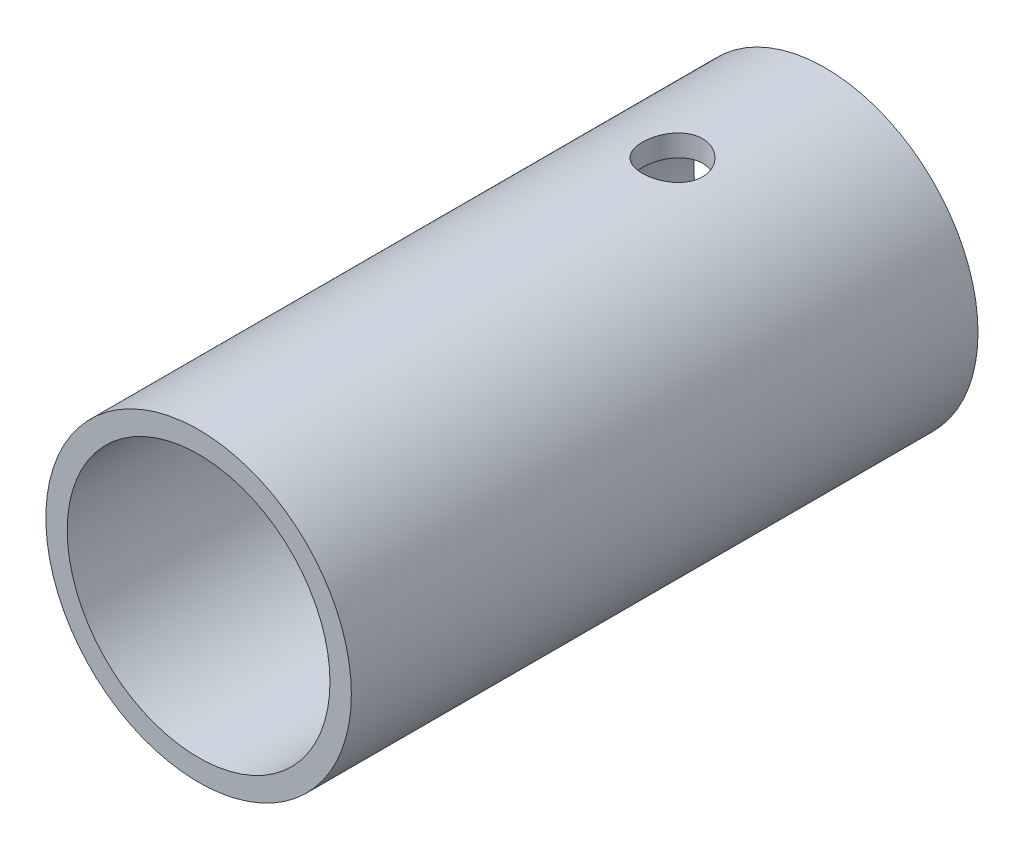
from build123d import *

# Parameters (mm, degrees)
SKETCH1_R               = 6.35
SKETCH1_R_2             = 5.461
EXTRUDE1_DEPTH          = 26.05
CUT_EXTRUDE1_DEPTH      = 38.1
CUT_EXTRUDE1_DEPTH_BACK = 38.1
SKETCH2_R               = 1.25


with BuildPart() as part:
    # Sketch1 → Extrude1 (new body)
    with BuildSketch(Plane.XY):
        Circle(SKETCH1_R)
        Circle(SKETCH1_R_2, mode=Mode.SUBTRACT)
    extrude(amount=EXTRUDE1_DEPTH)

    # Sketch2 → Cut-Extrude1 (cut, two sides: drawn at the far end of the back side and taken through both)
    with BuildSketch(Plane(origin=(0, 0, 0), x_dir=(1, 0, 0), z_dir=(0, 1, 0)).offset(-CUT_EXTRUDE1_DEPTH_BACK)):
        with Locations((0, -6.35)):
            Circle(SKETCH2_R)
    extrude(amount=CUT_EXTRUDE1_DEPTH + CUT_EXTRUDE1_DEPTH_BACK, mode=Mode.SUBTRACT)


solid = part.part
